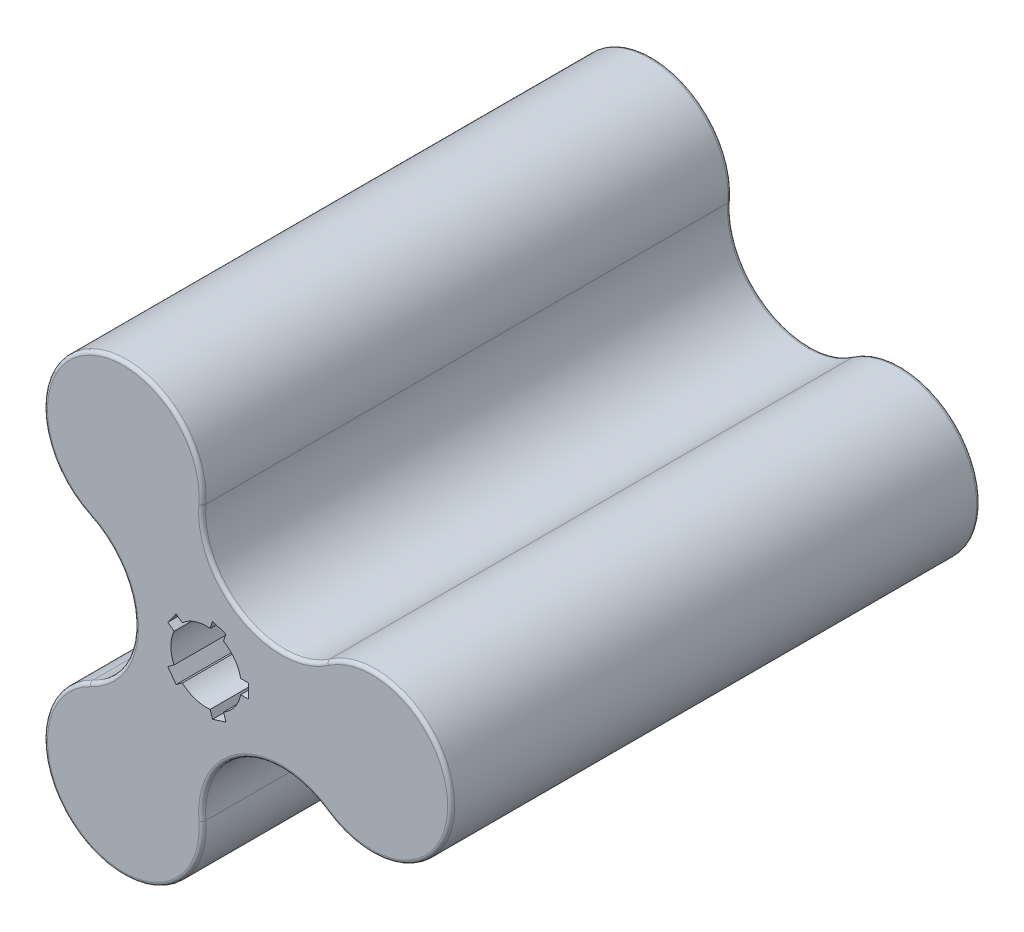
from build123d import *

# Parameters (mm, degrees)
SKETCH1_R           = 22.5
BOSS_EXTRUDE1_DEPTH = 75
FILLET1_R           = 1


with BuildPart() as part:
    # Sketch1 → Boss-Extrude1 (new body, symmetric)
    with BuildSketch(Plane.XY):
        with Locations((-23.5, 40.703193978)):
            Circle(SKETCH1_R)
        with Locations((47, 0)):
            Circle(SKETCH1_R)
        with Locations((-23.5, -40.703193978)):
            Circle(SKETCH1_R)
        with BuildLine():
            ThreePointArc((34.172460266, -18.485243422), (24.5, 0), (34.172460266, 18.485243422))
            ThreePointArc((34.172460266, 18.485243422), (10.094920531, 17.484915258), (-1.077539734, 38.836840411))
            ThreePointArc((-1.077539734, 38.836840411), (-12.25, 21.217622393), (-33.094920531, 20.351596989))
            ThreePointArc((-33.094920531, 20.351596989), (-20.189841062, 0), (-33.094920531, -20.351596989))
            ThreePointArc((-33.094920531, -20.351596989), (-12.25, -21.217622393), (-1.077539734, -38.836840411))
            ThreePointArc((-1.077539734, -38.836840411), (10.094920531, -17.484915258), (34.172460266, -18.485243422))
        make_face()
        with BuildLine():
            Line((1.8060909, -12.030712184), (1.1256228, -9.936446715))
            ThreePointArc((1.1256228, -9.936446715), (-3.090169944, -9.510565163), (-6.751144813, -7.377129775))
            Line((-6.751144813, -7.377129775), (-8.532633428, -8.671457016))
            Line((-8.532633428, -8.671457016), (-10.883774437, -5.435389039))
            Line((-10.883774437, -5.435389039), (-9.102285822, -4.141061797))
            ThreePointArc((-9.102285822, -4.141061797), (-10, 0), (-9.102285822, 4.141061797))
            Line((-9.102285822, 4.141061797), (-10.883774437, 5.435389039))
            Line((-10.883774437, 5.435389039), (-8.532633428, 8.671457016))
            Line((-8.532633428, 8.671457016), (-6.751144813, 7.377129775))
            ThreePointArc((-6.751144813, 7.377129775), (-3.090169944, 9.510565163), (1.1256228, 9.936446715))
            Line((1.1256228, 9.936446715), (1.8060909, 12.030712184))
            Line((1.8060909, 12.030712184), (5.610316965, 10.794644207))
            Line((5.610316965, 10.794644207), (4.929848865, 8.700378737))
            ThreePointArc((4.929848865, 8.700378737), (8.090169944, 5.877852523), (9.797958971, 2))
            Line((9.797958971, 2), (12, 2))
            Line((12, 2), (12, -2))
            Line((12, -2), (9.797958971, -2))
            ThreePointArc((9.797958971, -2), (8.090169944, -5.877852523), (4.929848865, -8.700378737))
            Line((4.929848865, -8.700378737), (5.610316965, -10.794644207))
            Line((5.610316965, -10.794644207), (1.8060909, -12.030712184))
        make_face(mode=Mode.SUBTRACT)
    extrude(amount=BOSS_EXTRUDE1_DEPTH, both=True)

    # Fillet1
    fillet1_edges = [part.edges().sort_by_distance(p)[0] for p in [
        (-34.75, -60.188765563, 75),
        (10.094920531, -17.484915258, 75),
        (69.5, 0, 75),
        (10.094920531, 17.484915258, 75),
        (10.094920531, 17.484915258, -75),
        (69.5, 0, -75),
        (10.094920531, -17.484915258, -75),
        (-34.75, -60.188765563, -75),
        (-20.189841062, 0, -75),
        (-34.75, 60.188765563, -75),
        (-34.75, 60.188765563, 75),
        (-20.189841062, 0, 75),
    ]]
    fillet(fillet1_edges, radius=FILLET1_R)


solid = part.part
